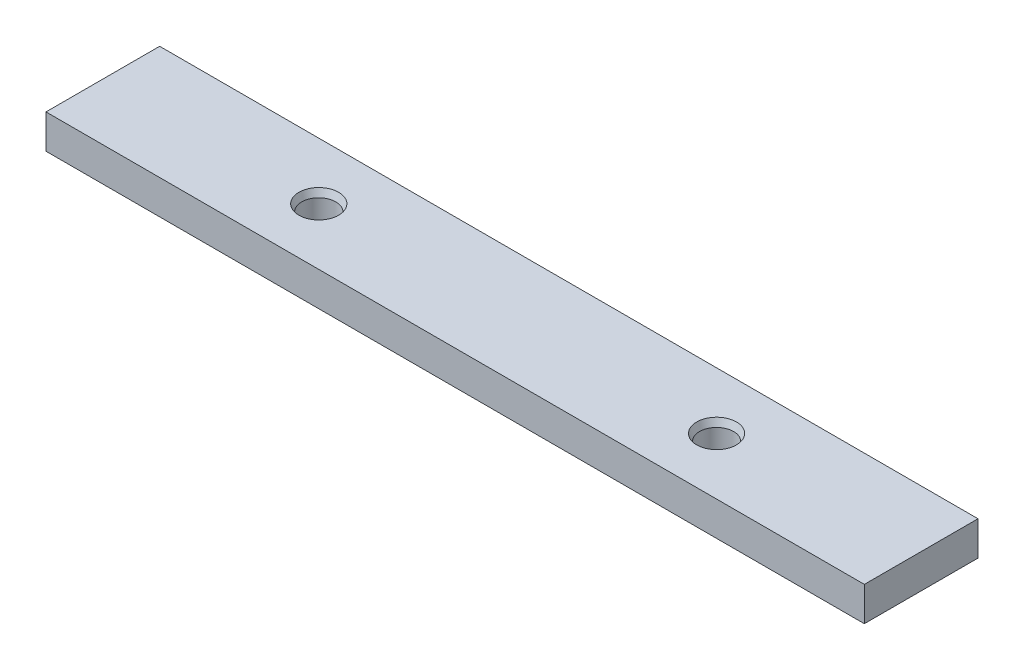
from build123d import *

# Parameters (mm, degrees)
SKETCH2_W                                      = 144
SKETCH2_H                                      = 20
BOSS_EXTRUDE1_DEPTH                            = 6
CSK_FOR_M2_FLAT_HEAD_MACHINE_SCREW2_AT_2_COUNT = 2
CSK_FOR_M2_FLAT_HEAD_MACHINE_SCREW2_AT_2_PITCH = 70


with BuildPart() as part:
    # Sketch2 → Boss-Extrude1 (new body)
    with BuildSketch(Plane(origin=(0, 0, 0), x_dir=(1, 0, 0), z_dir=(0, 1, 0))):
        with Locations((72, 10)):
            Rectangle(SKETCH2_W, SKETCH2_H)
    extrude(amount=BOSS_EXTRUDE1_DEPTH)

    # Sketch6 → CSK for M2 Flat Head Machine Screw2 (revolve, cut)
    with BuildSketch(Plane(origin=(38, 6, -10), x_dir=(0, 0, 1), z_dir=(1, 0, 0))):
        Polygon((0, 0), (0, 6), (3, 6), (3, 1.207106781), (3.5, 0), align=None)
    csk_for_m2_flat_head_machine_screw2 = revolve(axis=Axis((38, 12.35, -10), (0, -1, 0)), mode=Mode.SUBTRACT)

    # CSK for M2 Flat Head Machine Screw2 at 2: CSK for M2 Flat Head Machine Screw2 ×2
    with Locations(*[(i * CSK_FOR_M2_FLAT_HEAD_MACHINE_SCREW2_AT_2_PITCH, 0, 0) for i in range(1, CSK_FOR_M2_FLAT_HEAD_MACHINE_SCREW2_AT_2_COUNT)]):
        add(csk_for_m2_flat_head_machine_screw2, mode=Mode.SUBTRACT)


solid = part.part
